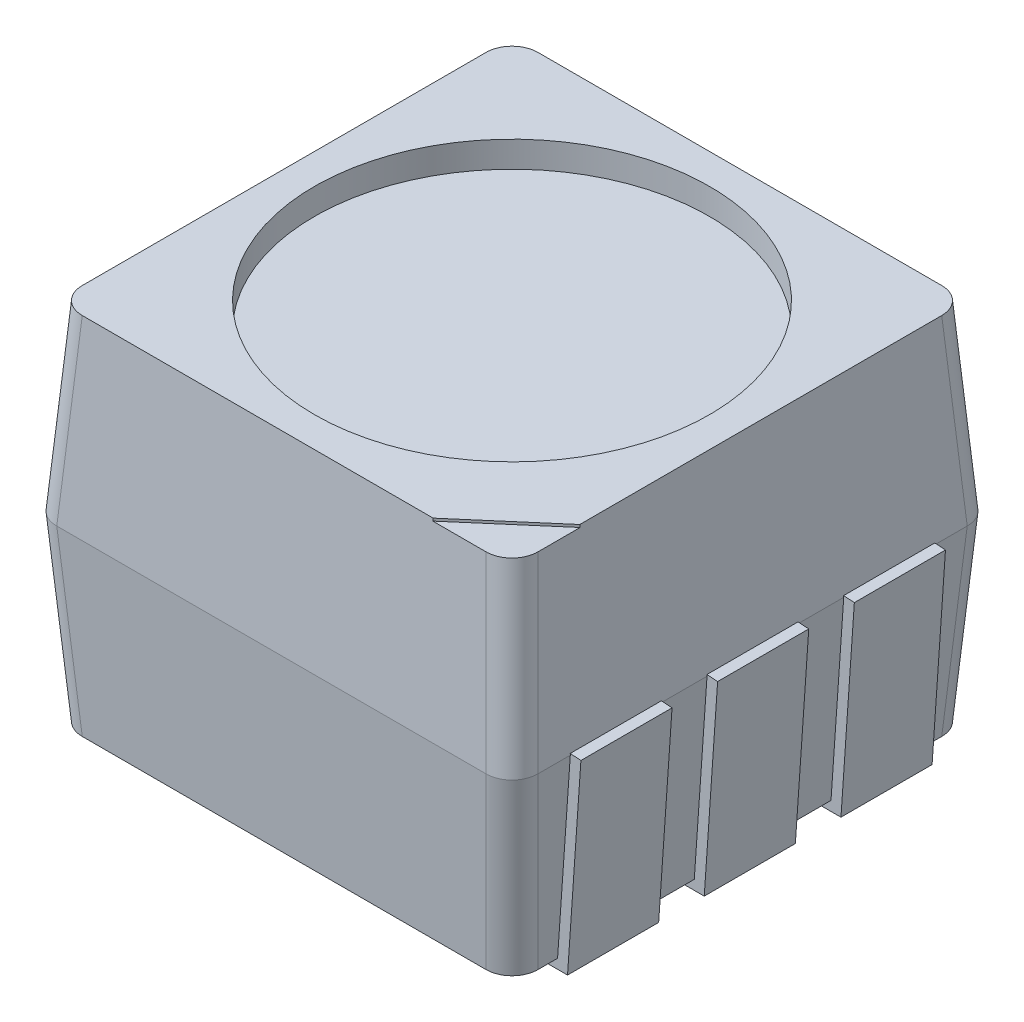
from build123d import *

# Parameters (mm, degrees)
SKETCH1_W            = 3.5
SKETCH1_H            = 3.5
BOSS_EXTRUDE1_DEPTH  = 1.4
BOSS_EXTRUDE1_TAPER  = -4
SKETCH2_W            = 3.695795074
SKETCH2_H            = 3.695795074
BOSS_EXTRUDE2_DEPTH  = 1.4
BOSS_EXTRUDE2_TAPER  = 4
FILLET1_R            = 0.2
SKETCH3_R            = 1.517913715
CUT_EXTRUDE1_DEPTH   = 0.2
EXTRUDE_THIN1_DEPTH  = 0.35
LPATTERN1_COUNT      = 2
LPATTERN1_PITCH      = 1.05
LPATTERN2_COUNT      = 2
LPATTERN2_PITCH      = 1.05
MIRROR1_COPY_1_DEPTH = 0.35
MIRROR1_COPY_2_DEPTH = 0.35
CUT_EXTRUDE2_DEPTH   = 0.02


with BuildPart() as part:
    # Sketch1 → Boss-Extrude1 (new body)
    with BuildSketch(Plane(origin=(0, 0, 0), x_dir=(1, 0, 0), z_dir=(0, 1, 0))):
        Rectangle(SKETCH1_W, SKETCH1_H)
    extrude(amount=BOSS_EXTRUDE1_DEPTH, taper=BOSS_EXTRUDE1_TAPER)

    # Sketch2 → Boss-Extrude2 (add)
    with BuildSketch(Plane(origin=(0, 1.4, 0), x_dir=(1, 0, 0), z_dir=(0, 1, 0))):
        Rectangle(SKETCH2_W, SKETCH2_H)
    extrude(amount=BOSS_EXTRUDE2_DEPTH, taper=BOSS_EXTRUDE2_TAPER)

    # Fillet1
    fillet1_edges = [part.edges().sort_by_distance(p)[0] for p in [
        (-1.798948768, 2.1, 1.798948768),
        (1.798948768, 2.1, 1.798948768),
        (1.798948768, 2.1, -1.798948768),
        (-1.798948768, 2.1, -1.798948768),
        (1.798948768, 0.7, 1.798948768),
        (-1.798948768, 0.7, 1.798948768),
        (-1.798948768, 0.7, -1.798948768),
        (1.798948768, 0.7, -1.798948768),
    ]]
    fillet(fillet1_edges, radius=FILLET1_R)

    # Sketch3 → Cut-Extrude1 (cut)
    with BuildSketch(Plane(origin=(0, 2.8, 0), x_dir=(1, 0, 0), z_dir=(0, 1, 0))):
        Circle(SKETCH3_R)
    extrude(amount=-CUT_EXTRUDE1_DEPTH, mode=Mode.SUBTRACT)

    # Sketch4 → Extrude-Thin1 (add, symmetric)
    with BuildSketch(Plane.XY):
        Polygon((-1.929260437, 1.405319652), (-1.826413832, -0.073543587), (-1.076413832, -0.073543587), (-1.076413832, 0.126456413), (-1.639839647, 0.126456413), (-1.729742331, 1.419195012), align=None)
    extrude_thin1 = extrude(amount=EXTRUDE_THIN1_DEPTH, both=True)

    # LPattern1: Extrude-Thin1 ×2
    with Locations(*[(0, 0, i * LPATTERN1_PITCH) for i in range(1, LPATTERN1_COUNT)]):
        add(extrude_thin1)

    # LPattern2: Extrude-Thin1 ×2
    with Locations(*[(0, 0, -i * LPATTERN2_PITCH) for i in range(1, LPATTERN2_COUNT)]):
        add(extrude_thin1)

    # Mirror1: Extrude-Thin1 across plane
    add(extrude_thin1.mirror(Plane(origin=(0, 0, 0), x_dir=(0, 0, 1), z_dir=(1, 0, 0))))

    # Mirror1 copy 1 sketch → Mirror1 copy 1 (add, symmetric)
    with BuildSketch(Plane(origin=(0, 0, 1.05), x_dir=(-1, 0, 0), z_dir=(0, 0, 1))):
        Polygon((-1.929260437, -1.405319652), (-1.826413832, 0.073543587), (-1.076413832, 0.073543587), (-1.076413832, -0.126456413), (-1.639839647, -0.126456413), (-1.729742331, -1.419195012), align=None)
    extrude(amount=MIRROR1_COPY_1_DEPTH, both=True)

    # Mirror1 copy 2 sketch → Mirror1 copy 2 (add, symmetric)
    with BuildSketch(Plane(origin=(0, 0, -1.05), x_dir=(-1, 0, 0), z_dir=(0, 0, 1))):
        Polygon((-1.929260437, -1.405319652), (-1.826413832, 0.073543587), (-1.076413832, 0.073543587), (-1.076413832, -0.126456413), (-1.639839647, -0.126456413), (-1.729742331, -1.419195012), align=None)
    extrude(amount=MIRROR1_COPY_2_DEPTH, both=True)

    # Sketch5 → Cut-Extrude2 (cut)
    with BuildSketch(Plane(origin=(0, 2.8, 0), x_dir=(1, 0, 0), z_dir=(0, 1, 0))):
        Polygon((1.991844577, -1.021164559), (0.940848245, -1.925296774), (2.028560606, -1.925296774), align=None)
    extrude(amount=-CUT_EXTRUDE2_DEPTH, mode=Mode.SUBTRACT)


solid = part.part
